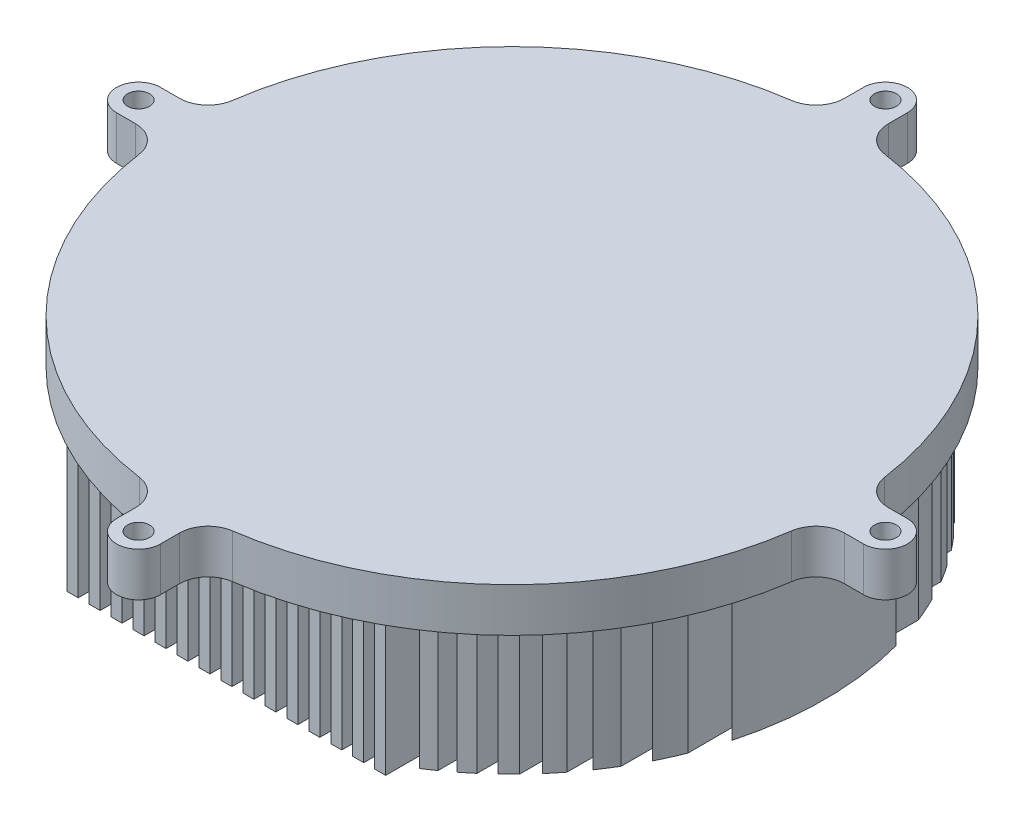
from build123d import *

# Parameters (mm, degrees)
SKETCH3_R           = 5
BOSS_EXTRUDE4_DEPTH = 20
SKETCH4_W           = 5
SKETCH4_H           = 260
BOSS_EXTRUDE5_DEPTH = 60


with BuildPart() as part:
    # Sketch3 → Boss-Extrude4 (new body)
    with BuildSketch(Plane(origin=(0, 0, 0), x_dir=(1, 0, 0), z_dir=(0, 1, 0))):
        with BuildLine():
            Line((161.369142032, 10), (170, 10))
            ThreePointArc((170, 10), (180, 0), (170, -10))
            Line((170, -10), (161.369142032, -10))
            ThreePointArc((161.369142032, -10), (152.849946816, -13.180462695), (148.499210458, -21.165644172))
            ThreePointArc((148.499210458, -21.165644172), (106.066017178, -106.066017178), (21.165644172, -148.499210458))
            ThreePointArc((21.165644172, -148.499210458), (13.180462695, -152.849946816), (10, -161.369142032))
            Line((10, -161.369142032), (10, -170))
            ThreePointArc((10, -170), (0, -180), (-10, -170))
            Line((-10, -170), (-10, -161.369142032))
            ThreePointArc((-10, -161.369142032), (-13.180462695, -152.849946816), (-21.165644172, -148.499210458))
            ThreePointArc((-21.165644172, -148.499210458), (-106.066017178, -106.066017178), (-148.499210458, -21.165644172))
            ThreePointArc((-148.499210458, -21.165644172), (-152.849946816, -13.180462695), (-161.369142032, -10))
            Line((-161.369142032, -10), (-170, -10))
            ThreePointArc((-170, -10), (-180, 0), (-170, 10))
            Line((-170, 10), (-161.369142032, 10))
            ThreePointArc((-161.369142032, 10), (-152.849946816, 13.180462695), (-148.499210458, 21.165644172))
            ThreePointArc((-148.499210458, 21.165644172), (-106.066017178, 106.066017178), (-21.165644172, 148.499210458))
            ThreePointArc((-21.165644172, 148.499210458), (-13.180462695, 152.849946816), (-10, 161.369142032))
            Line((-10, 161.369142032), (-10, 170))
            ThreePointArc((-10, 170), (0, 180), (10, 170))
            Line((10, 170), (10, 161.369142032))
            ThreePointArc((10, 161.369142032), (13.180462695, 152.849946816), (21.165644172, 148.499210458))
            ThreePointArc((21.165644172, 148.499210458), (106.066017178, 106.066017178), (148.499210458, 21.165644172))
            ThreePointArc((148.499210458, 21.165644172), (152.849946816, 13.180462695), (161.369142032, 10))
        make_face()
        with Locations((0, 170)):
            Circle(SKETCH3_R, mode=Mode.SUBTRACT)
        with Locations((170, 0)):
            Circle(SKETCH3_R, mode=Mode.SUBTRACT)
        with Locations((0, -170)):
            Circle(SKETCH3_R, mode=Mode.SUBTRACT)
        with Locations((-170, 0)):
            Circle(SKETCH3_R, mode=Mode.SUBTRACT)
    extrude(amount=-BOSS_EXTRUDE4_DEPTH)

    # Sketch4 → Boss-Extrude5 (add)
    with BuildSketch(Plane(origin=(0, -20, 0), x_dir=(1, 0, 0), z_dir=(0, 1, 0))):
        Rectangle(SKETCH4_W, SKETCH4_H)
        with Locations((10, 0)):
            Rectangle(SKETCH4_W, SKETCH4_H)
        with Locations((20, 0)):
            Rectangle(SKETCH4_W, SKETCH4_H)
        with Locations((30, 0)):
            Rectangle(SKETCH4_W, SKETCH4_H)
        with Locations((40, 0)):
            Rectangle(SKETCH4_W, SKETCH4_H)
        with Locations((50, 0)):
            Rectangle(SKETCH4_W, SKETCH4_H)
        with Locations((60, 0)):
            Rectangle(SKETCH4_W, SKETCH4_H)
        with Locations((70, 0)):
            Rectangle(SKETCH4_W, SKETCH4_H)
        with BuildLine():
            Line((82.5, 116.189500386), (82.5, -116.189500386))
            ThreePointArc((82.5, -116.189500386), (80.017987314, -117.912559578), (77.5, -119.582607431))
            Line((77.5, -119.582607431), (77.5, 119.582607431))
            ThreePointArc((77.5, 119.582607431), (80.017987314, 117.912559578), (82.5, 116.189500386))
        make_face()
        with BuildLine():
            Line((92.5, 108.397416943), (92.5, -108.397416943))
            ThreePointArc((92.5, -108.397416943), (90.023058171, -110.463111478), (87.5, -112.472218792))
            Line((87.5, -112.472218792), (87.5, 112.472218792))
            ThreePointArc((87.5, 112.472218792), (90.023058171, 110.463111478), (92.5, 108.397416943))
        make_face()
        with BuildLine():
            Line((102.5, 98.994949366), (102.5, -98.994949366))
            ThreePointArc((102.5, -98.994949366), (100.030353094, -101.489794856), (97.5, -103.923048454))
            Line((97.5, -103.923048454), (97.5, 103.923048454))
            ThreePointArc((97.5, 103.923048454), (100.030353094, 101.489794856), (102.5, 98.994949366))
        make_face()
        with BuildLine():
            Line((112.5, 87.464278423), (112.5, -87.464278423))
            ThreePointArc((112.5, -87.464278423), (110.041959984, -90.537379258), (107.5, -93.541434669))
            Line((107.5, -93.541434669), (107.5, 93.541434669))
            ThreePointArc((107.5, 93.541434669), (110.041959984, 90.537379258), (112.5, 87.464278423))
        make_face()
        with Locations((-10, 0)):
            Rectangle(SKETCH4_W, SKETCH4_H)
        with Locations((-20, 0)):
            Rectangle(SKETCH4_W, SKETCH4_H)
        with Locations((-30, 0)):
            Rectangle(SKETCH4_W, SKETCH4_H)
        with Locations((-40, 0)):
            Rectangle(SKETCH4_W, SKETCH4_H)
        with Locations((-50, 0)):
            Rectangle(SKETCH4_W, SKETCH4_H)
        with Locations((-60, 0)):
            Rectangle(SKETCH4_W, SKETCH4_H)
        with Locations((-70, 0)):
            Rectangle(SKETCH4_W, SKETCH4_H)
        with BuildLine():
            Line((-82.5, 116.189500386), (-82.5, -116.189500386))
            ThreePointArc((-82.5, -116.189500386), (-80.017987314, -117.912559578), (-77.5, -119.582607431))
            Line((-77.5, -119.582607431), (-77.5, 119.582607431))
            ThreePointArc((-77.5, 119.582607431), (-80.017987314, 117.912559578), (-82.5, 116.189500386))
        make_face()
        with BuildLine():
            Line((-92.5, 108.397416943), (-92.5, -108.397416943))
            ThreePointArc((-92.5, -108.397416943), (-90.023058171, -110.463111478), (-87.5, -112.472218792))
            Line((-87.5, -112.472218792), (-87.5, 112.472218792))
            ThreePointArc((-87.5, 112.472218792), (-90.023058171, 110.463111478), (-92.5, 108.397416943))
        make_face()
        with BuildLine():
            Line((-102.5, 98.994949366), (-102.5, -98.994949366))
            ThreePointArc((-102.5, -98.994949366), (-100.030353094, -101.489794856), (-97.5, -103.923048454))
            Line((-97.5, -103.923048454), (-97.5, 103.923048454))
            ThreePointArc((-97.5, 103.923048454), (-100.030353094, 101.489794856), (-102.5, 98.994949366))
        make_face()
        with BuildLine():
            Line((-112.5, 87.464278423), (-112.5, -87.464278423))
            ThreePointArc((-112.5, -87.464278423), (-110.041959984, -90.537379258), (-107.5, -93.541434669))
            Line((-107.5, -93.541434669), (-107.5, 93.541434669))
            ThreePointArc((-107.5, 93.541434669), (-110.041959984, 90.537379258), (-112.5, 87.464278423))
        make_face()
        with BuildLine():
            Line((-122.5, 72.801098893), (-122.5, -72.801098893))
            ThreePointArc((-122.5, -72.801098893), (-120.063707597, -76.752564245), (-117.5, -80.622577483))
            Line((-117.5, -80.622577483), (-117.5, 80.622577483))
            ThreePointArc((-117.5, 80.622577483), (-120.063707597, 76.752564245), (-122.5, 72.801098893))
        make_face()
        with BuildLine():
            Line((-132.5, 52.440442409), (-132.5, -52.440442409))
            ThreePointArc((-132.5, -52.440442409), (-130.120541577, -58.09384356), (-127.5, -63.639610307))
            Line((-127.5, -63.639610307), (-127.5, 63.639610307))
            ThreePointArc((-127.5, 63.639610307), (-130.120541577, 58.09384356), (-132.5, 52.440442409))
        make_face()
        with BuildLine():
            Line((-137.5, 37.416573868), (-137.5, -37.416573868))
            ThreePointArc((-137.5, -37.416573868), (-142.5, 0), (-137.5, 37.416573868))
        make_face()
        with BuildLine():
            Line((122.5, 72.801098893), (122.5, -72.801098893))
            ThreePointArc((122.5, -72.801098893), (120.063707597, -76.752564245), (117.5, -80.622577483))
            Line((117.5, -80.622577483), (117.5, 80.622577483))
            ThreePointArc((117.5, 80.622577483), (120.063707597, 76.752564245), (122.5, 72.801098893))
        make_face()
        with BuildLine():
            Line((132.5, 52.440442409), (132.5, -52.440442409))
            ThreePointArc((132.5, -52.440442409), (130.120541577, -58.09384356), (127.5, -63.639610307))
            Line((127.5, -63.639610307), (127.5, 63.639610307))
            ThreePointArc((127.5, 63.639610307), (130.120541577, 58.09384356), (132.5, 52.440442409))
        make_face()
        with BuildLine():
            Line((137.5, 37.416573868), (137.5, -37.416573868))
            ThreePointArc((137.5, -37.416573868), (142.5, 0), (137.5, 37.416573868))
        make_face()
    extrude(amount=-BOSS_EXTRUDE5_DEPTH)


solid = part.part
